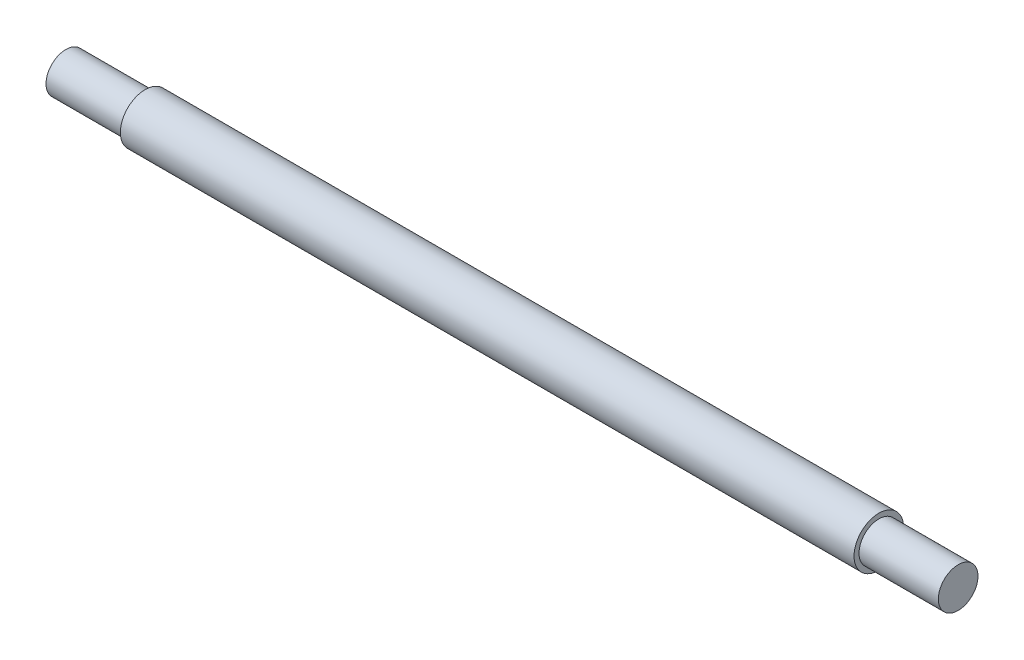
from build123d import *

# Parameters (mm, degrees)
SKETCH1_R           = 2.5
BOSS_EXTRUDE1_DEPTH = 45
SKETCH2_R           = 2.5
SKETCH2_R_2         = 2
CUT_EXTRUDE1_DEPTH  = 8
SKETCH3_R           = 2.5
SKETCH3_R_2         = 2
CUT_EXTRUDE2_DEPTH  = 8


with BuildPart() as part:
    # Sketch1 → Boss-Extrude1 (new body, symmetric)
    with BuildSketch(Plane(origin=(0, 0, 0), x_dir=(0, 0, -1), z_dir=(1, 0, 0))):
        Circle(SKETCH1_R)
    extrude(amount=BOSS_EXTRUDE1_DEPTH, both=True)

    # Sketch2 → Cut-Extrude1 (cut)
    with BuildSketch(Plane(origin=(45, 0, 0), x_dir=(0, 0, -1), z_dir=(1, 0, 0))):
        Circle(SKETCH2_R)
        Circle(SKETCH2_R_2, mode=Mode.SUBTRACT)
    extrude(amount=-CUT_EXTRUDE1_DEPTH, mode=Mode.SUBTRACT)

    # Sketch3 → Cut-Extrude2 (cut)
    with BuildSketch(Plane.ZY.offset(45)):
        Circle(SKETCH3_R)
        Circle(SKETCH3_R_2, mode=Mode.SUBTRACT)
    extrude(amount=-CUT_EXTRUDE2_DEPTH, mode=Mode.SUBTRACT)


solid = part.part
